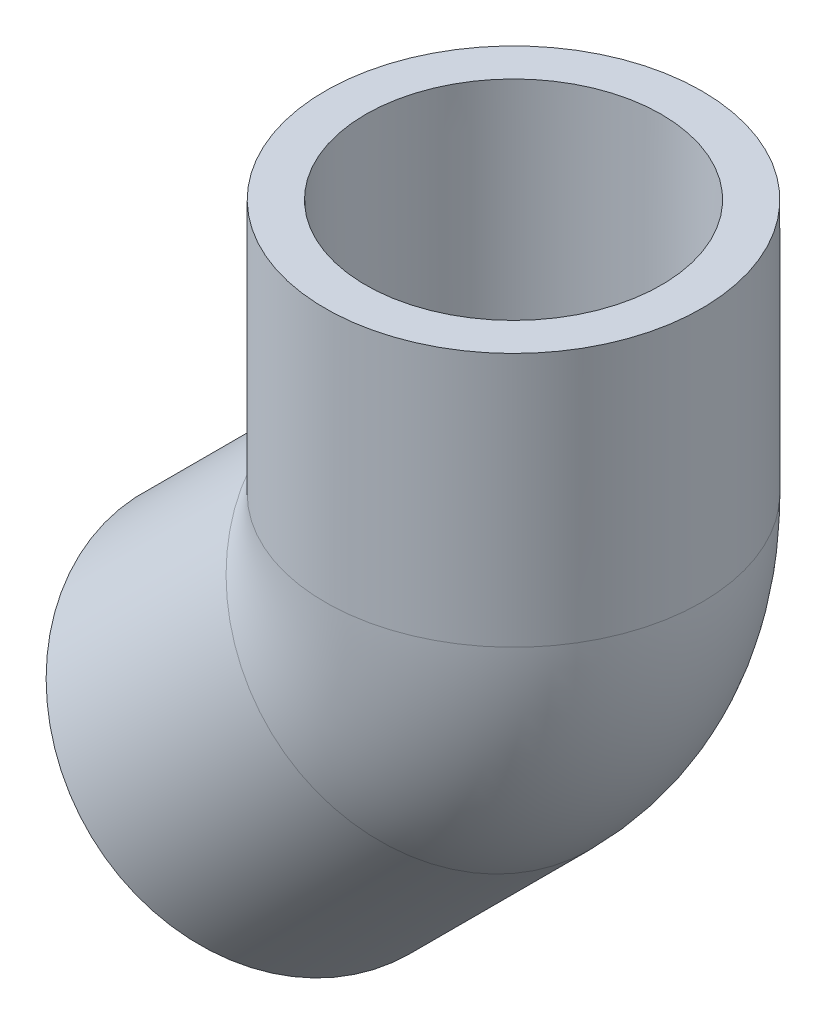
from build123d import *

# Parameters (mm, degrees)
SKETCH3_R   = 21.43125
SKETCH3_R_2 = 12.1539


with BuildPart() as part:
    # Sketch1 → Revolve1 (revolve)
    with BuildSketch(Plane.XY):
        Polygon((-11.786586159, -42.094950568), (8.688397797, -21.619966611), (5.298351111, -18.229919926), (-15.041929003, -38.839607724), align=None)
    revolve(axis=Axis((-26.940768363, -26.940768363, 0), (0.707106781186549, 0.7071067811865461, 0)))



with BuildPart() as body_2:
    # Sketch2 → Revolve2 (revolve)
    with BuildSketch(Plane.XY):
        Polygon((16.8275, 38.1), (16.637, 9.144), (21.43125, 9.144), (21.43125, 38.1), align=None)
    revolve(axis=Axis((0, 0, 0), (0, 1, 0)))


with BuildPart() as part_1:
    add(part.part)

    add(body_2.part)  # Sweep1 merges body 2
    # Sweep1: sweep along a path in Sketch4
    with BuildLine(Plane.XY) as sweep1_path:
        ThreePointArc((-6.465784407, -6.465784407), (-1.680402618, 0.696045555), (0, 9.144))
    # Sketch3 → Sweep1 (sweep)
    with BuildSketch(Plane(origin=(-6.465784407, -6.465784407, 0), x_dir=(0, 0, -1), z_dir=(0.7071067811865488, 0.7071067811865464, 0))):
        Circle(SKETCH3_R)
        Circle(SKETCH3_R_2, mode=Mode.SUBTRACT)
    sweep(path=sweep1_path.line)


solid = part_1.part
